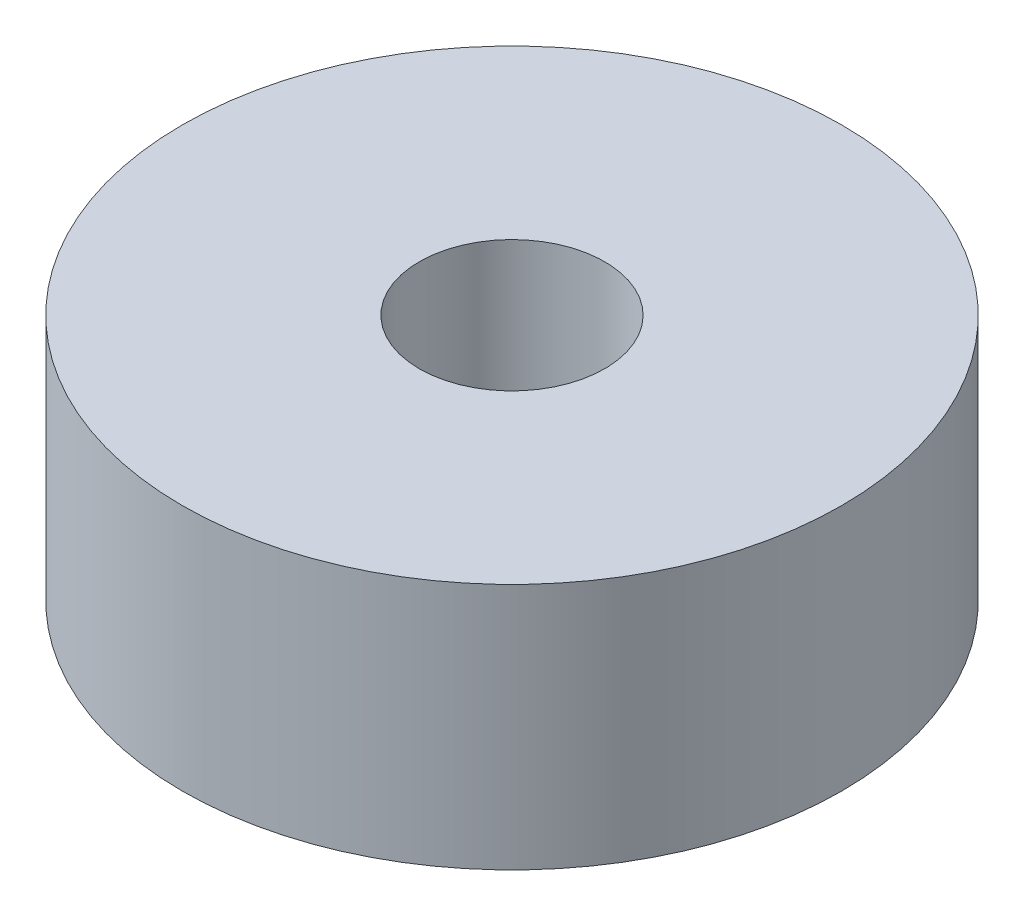
from build123d import *

# Parameters (mm, degrees)
SKETCH1_R           = 8
SKETCH1_R_2         = 2.25
BOSS_EXTRUDE1_DEPTH = 6


with BuildPart() as part:
    # Sketch1 → Boss-Extrude1 (new body)
    with BuildSketch(Plane(origin=(0, 0, 0), x_dir=(1, 0, 0), z_dir=(0, 1, 0))):
        Circle(SKETCH1_R)
        Circle(SKETCH1_R_2, mode=Mode.SUBTRACT)
    extrude(amount=BOSS_EXTRUDE1_DEPTH)


solid = part.part
